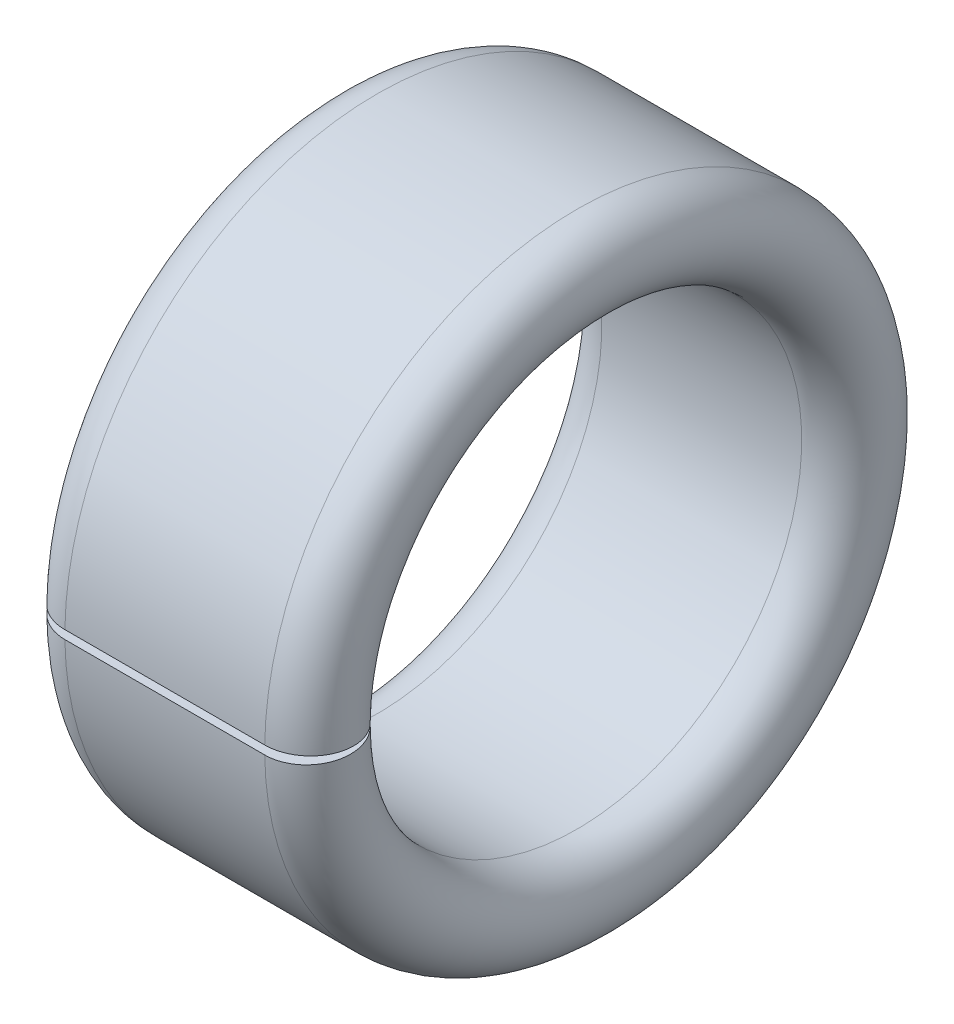
from build123d import *

# Parameters (mm, degrees)
CUT_EXTRUDE1_DEPTH = 2.3


with BuildPart() as part:
    # Sketch1 → Revolve1 (revolve)
    with BuildSketch(Plane.XY):
        with BuildLine():
            Line((0.35, 1.8), (1.95, 1.8))
            ThreePointArc((1.95, 1.8), (2.3, 2.15), (1.95, 2.5))
            Line((1.95, 2.5), (0.35, 2.5))
            ThreePointArc((0.35, 2.5), (0, 2.15), (0.35, 1.8))
        make_face()
    revolve(axis=Axis((2.3, 0, 0), (-1, 0, 0)))

    # Sketch2 → Cut-Extrude1 (cut)
    with BuildSketch(Plane(origin=(0, 0, 0), x_dir=(0, 0, -1), z_dir=(1, 0, 0))):
        with BuildLine():
            Line((-3.499313025, -0.069342288), (-1.513609689, 0))
            Line((-1.513609689, 0), (-3.499313025, 0.069342288))
            ThreePointArc((-3.499313025, 0.069342288), (-3.5, 0), (-3.499313025, -0.069342288))
        make_face()
    extrude(amount=CUT_EXTRUDE1_DEPTH, mode=Mode.SUBTRACT)


solid = part.part
